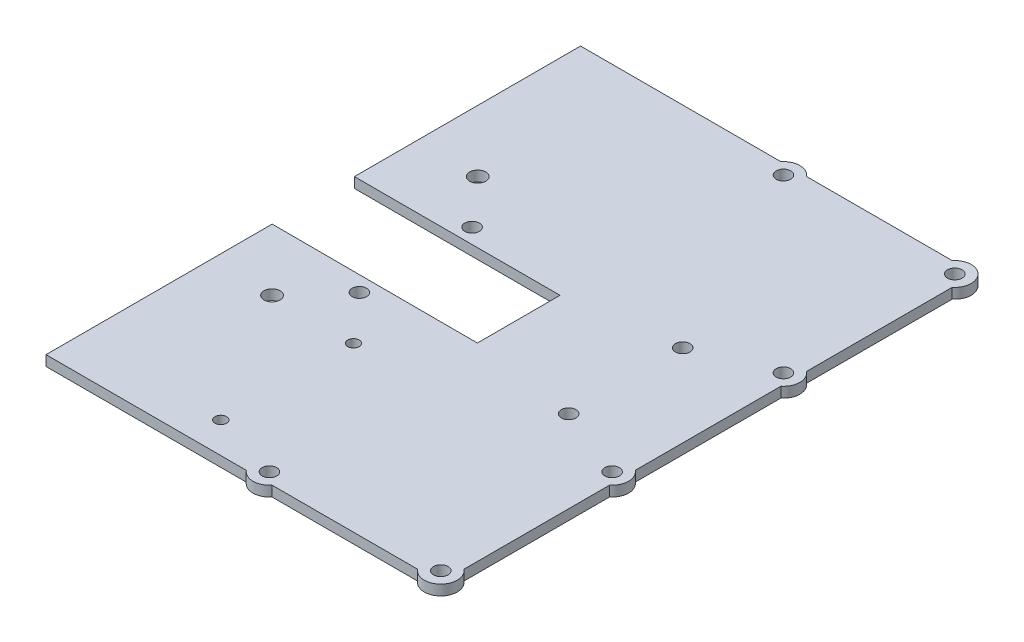
from build123d import *

# Parameters (mm, degrees)
SKETCH1_R           = 2.2479
BOSS_EXTRUDE1_DEPTH = 3.175
SKETCH2_R           = 2.4892
SKETCH2_R_2         = 2.2479
CUT_EXTRUDE1_DEPTH  = 4.175
SKETCH3_R           = 1.778
CUT_EXTRUDE2_DEPTH  = 4.175


with BuildPart() as part:
    # Sketch1 → Boss-Extrude1 (new body)
    with BuildSketch(Plane(origin=(0, 0, 0), x_dir=(1, 0, 0), z_dir=(0, 1, 0))):
        with BuildLine():
            Line((0, 165.1), (61.874509804, 165.1))
            ThreePointArc((61.874509804, 165.1), (65.840083533, 167.005), (69.805657262, 165.1))
            Line((69.805657262, 165.1), (114.791176471, 165.1))
            ThreePointArc((114.791176471, 165.1), (122.348852648, 165.517102448), (121.9317502, 157.959426271))
            Line((121.9317502, 157.959426271), (121.9317502, 112.973907062))
            ThreePointArc((121.9317502, 112.973907062), (123.8367502, 109.008333333), (121.9317502, 105.042759604))
            Line((121.9317502, 105.042759604), (121.9317502, 60.057240396))
            ThreePointArc((121.9317502, 60.057240396), (123.8367502, 56.091666667), (121.9317502, 52.126092938))
            Line((121.9317502, 52.126092938), (121.9317502, 7.140573729))
            ThreePointArc((121.9317502, 7.140573729), (122.348852648, -0.417102448), (114.791176471, 0))
            Line((114.791176471, 0), (69.805657262, 0))
            ThreePointArc((69.805657262, 0), (65.840083533, -1.905), (61.874509804, 0))
            Line((61.874509804, 0), (0, 0))
            Line((0, 0), (0, 69.85))
            Line((0, 69.85), (63.5, 69.72449217))
            Line((63.5, 69.72449217), (63.5, 95.25))
            Line((63.5, 95.25), (0, 95.25))
            Line((0, 95.25), (0, 165.1))
        make_face()
        with Locations((65.840083533, 3.175)):
            Circle(SKETCH1_R, mode=Mode.SUBTRACT)
        with Locations((118.7567502, 3.175)):
            Circle(SKETCH1_R, mode=Mode.SUBTRACT)
        with Locations((118.7567502, 56.091666667)):
            Circle(SKETCH1_R, mode=Mode.SUBTRACT)
        with Locations((118.7567502, 109.008333333)):
            Circle(SKETCH1_R, mode=Mode.SUBTRACT)
        with Locations((118.7567502, 161.925)):
            Circle(SKETCH1_R, mode=Mode.SUBTRACT)
        with Locations((65.840083533, 161.925)):
            Circle(SKETCH1_R, mode=Mode.SUBTRACT)
    extrude(amount=BOSS_EXTRUDE1_DEPTH)

    # Sketch2 → Cut-Extrude1 (cut, through all)
    with BuildSketch(Plane.XZ):
        with Locations((19.05, -50.762310441)):
            Circle(SKETCH2_R)
        with Locations((19.05, -114.3)):
            Circle(SKETCH2_R)
        with Locations((31.75, -65.024736783)):
            Circle(SKETCH2_R_2)
        with Locations((96.5317502, -64.896695572)):
            Circle(SKETCH2_R_2)
        with Locations((96.493890617, -100.14870612)):
            Circle(SKETCH2_R_2)
        with Locations((31.712564881, -99.881518123)):
            Circle(SKETCH2_R_2)
    extrude(amount=-CUT_EXTRUDE1_DEPTH, mode=Mode.SUBTRACT)

    # Sketch3 → Cut-Extrude2 (cut, through all)
    with BuildSketch(Plane(origin=(0, 3.175, 0), x_dir=(1, 0, 0), z_dir=(0, 1, 0))):
        with Locations((44.45, 9.525)):
            Circle(SKETCH3_R)
        with Locations((44.45, 50.525)):
            Circle(SKETCH3_R)
    extrude(amount=-CUT_EXTRUDE2_DEPTH, mode=Mode.SUBTRACT)


solid = part.part
